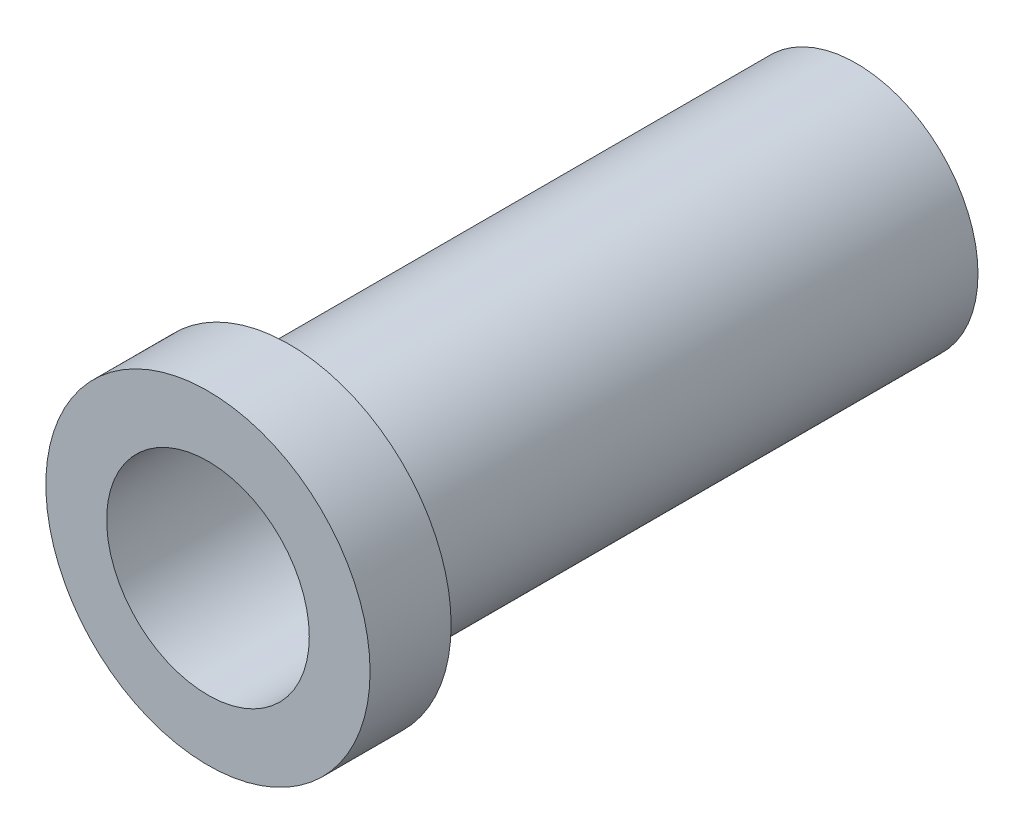
from build123d import *

# Parameters (mm, degrees)
SKETCH1_R           = 19.05
BOSS_EXTRUDE1_DEPTH = 101.6
SKETCH2_R           = 15.875
CUT_EXTRUDE1_DEPTH  = 101.6
SKETCH3_R           = 25.4
BOSS_EXTRUDE2_DEPTH = 12.7
SKETCH4_R           = 15.875
CUT_EXTRUDE2_DEPTH  = 12.7


with BuildPart() as part:
    # Sketch1 → Boss-Extrude1 (new body)
    with BuildSketch(Plane.XY):
        Circle(SKETCH1_R)
    extrude(amount=BOSS_EXTRUDE1_DEPTH)

    # Sketch2 → Cut-Extrude1 (cut)
    with BuildSketch(Plane.XY.offset(101.6)):
        Circle(SKETCH2_R)
    extrude(amount=-CUT_EXTRUDE1_DEPTH, mode=Mode.SUBTRACT)

    # Sketch3 → Boss-Extrude2 (add)
    with BuildSketch(Plane.XY.offset(101.6)):
        Circle(SKETCH3_R)
    extrude(amount=-BOSS_EXTRUDE2_DEPTH)

    # Sketch4 → Cut-Extrude2 (cut)
    with BuildSketch(Plane.XY.offset(101.6)):
        Circle(SKETCH4_R)
    extrude(amount=-CUT_EXTRUDE2_DEPTH, mode=Mode.SUBTRACT)


solid = part.part
